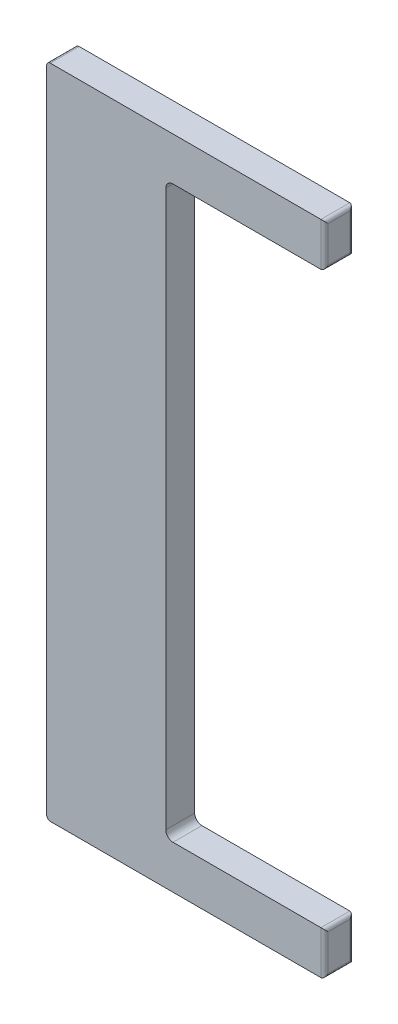
from build123d import *

# Parameters (mm, degrees)
BOSS_EXTRUDE1_DEPTH = 101.6
FILLET1_R           = 25.4
FILLET2_R           = 12.7


with BuildPart() as part:
    # Sketch1 → Boss-Extrude1 (new body)
    with BuildSketch(Plane.XY):
        Polygon((977.9, -152.4), (419.1, -152.4), (419.1, -2159), (977.9, -2159), (977.9, -2311.4), (0, -2311.4), (0, 0), (977.9, 0), align=None)
    extrude(amount=BOSS_EXTRUDE1_DEPTH)

    # Fillet1
    fillet1_edges = [part.edges().sort_by_distance(p)[0] for p in [
        (419.1, -152.4, 50.8),
        (419.1, -2159, 50.8),
    ]]
    fillet(fillet1_edges, radius=FILLET1_R)

    # Fillet2
    fillet2_edges = [part.edges().sort_by_distance(p)[0] for p in [
        (977.9, -2235.2, 101.6),
        (0, 0, 50.8),
        (977.9, 0, 50.8),
        (977.9, -152.4, 50.8),
        (977.9, -2159, 50.8),
        (977.9, -2311.4, 50.8),
        (0, -2311.4, 50.8),
        (977.9, -76.2, 101.6),
        (977.9, -76.2, 0),
        (977.9, -2235.2, 0),
    ]]
    fillet(fillet2_edges, radius=FILLET2_R)


solid = part.part
